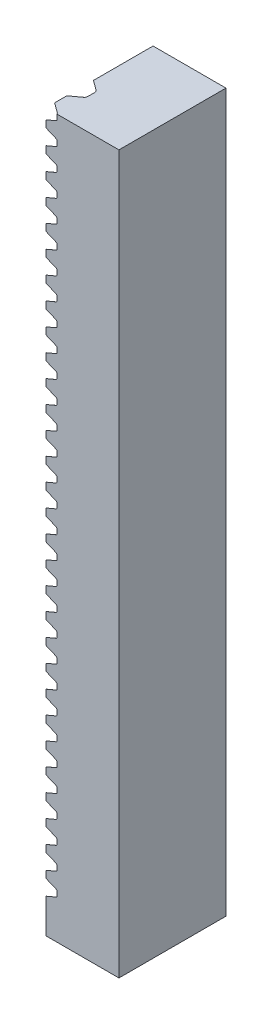
from build123d import *

# Parameters (mm, degrees)
EXTRUDECI_DEPTH            = 15
EXTRUDECI_DEPTH_BACK       = 15
SKETCHCI_M_STRSKETCHNAME_W = 20.435640625
SKETCHCI_M_STRSKETCHNAME_H = 201.06192681
HELICALTOOTHCUT_DEPTH      = 30
PATTERNSPURGEAR_COUNT      = 32
PATTERNSPURGEAR_PITCH      = 6.283185307


with BuildPart() as part:
    # SketchCI.m_strSketchName → ExtrudeCI (new, two sides: drawn at the far end of the back side and taken through both)
    with BuildSketch(Plane.XY.offset(-EXTRUDECI_DEPTH_BACK)):
        with Locations((8.832179688, -97.389370799)):
            Rectangle(SKETCHCI_M_STRSKETCHNAME_W, SKETCHCI_M_STRSKETCHNAME_H)
    extrude(amount=EXTRUDECI_DEPTH + EXTRUDECI_DEPTH_BACK)

    # RackToothSketch → HelicalToothCut (cut, symmetric)
    with BuildSketch(Plane(origin=(0, 0, 0), x_dir=(1, 0, 0), z_dir=(0, 0.5000000000000001, 0.8660254037844386))):
        with BuildLine():
            Line((-1.385640625, 1.864681446), (-1.385640625, -1.864681446))
            Line((-1.385640625, -1.864681446), (1.390154424, -0.854374671))
            ThreePointArc((1.390154424, -0.854374671), (1.638079429, -0.664135124), (1.732050782, -0.36609607))
            Line((1.732050782, -0.36609607), (1.732050782, 0.36609607))
            ThreePointArc((1.732050782, 0.36609607), (1.638079429, 0.664135124), (1.390154424, 0.854374671))
            Line((1.390154424, 0.854374671), (-1.385640625, 1.864681446))
        make_face()
    helicaltoothcut = extrude(amount=HELICALTOOTHCUT_DEPTH, both=True, mode=Mode.SUBTRACT)

    # PatternSpurGear: HelicalToothCut ×32
    with Locations(*[(0, -i * PATTERNSPURGEAR_PITCH, 0) for i in range(1, PATTERNSPURGEAR_COUNT)]):
        add(helicaltoothcut, mode=Mode.SUBTRACT)


solid = part.part
